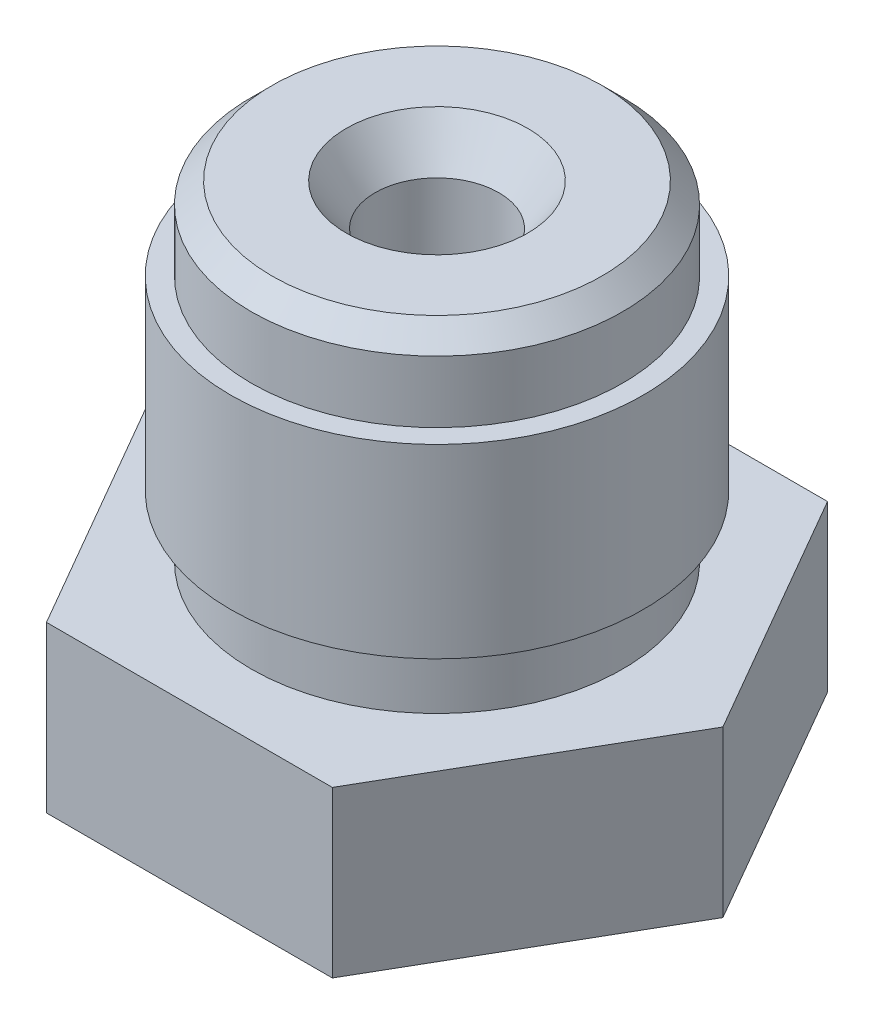
from build123d import *

# Parameters (mm, degrees)
SKETCH2_R           = 2.612661588
BOSS_EXTRUDE1_DEPTH = 2
CHAMFER1_SIZE       = 0.25


with BuildPart() as part:
    # Sketch1 → Revolve1 (revolve)
    with BuildSketch(Plane.XY):
        Polygon((0.2, -3.5), (0.2, -2.9), (0.75, -1.947372056), (0.75, 3), (1.100103769, 3.5), (2.25, 3.5), (2.25, 2.5), (2.5, 2.5), (2.5, 0.25), (2.25, 0.25), (2.25, -0.5), (3, -0.5), (3, -2.5), (1.100207538, -2.5), (0.4, -3.5), align=None)
    revolve(axis=Axis((0, -3.5, 0), (0, 1, 0)))

    # Sketch2 → Boss-Extrude1 (add)
    with BuildSketch(Plane.XZ.offset(2.5)):
        Polygon((1.732050808, 3), (-1.732050808, 3), (-3.464101615, 0), (-1.732050808, -3), (1.732050808, -3), (3.464101615, 0), align=None)
        Circle(SKETCH2_R, mode=Mode.SUBTRACT)
    extrude(amount=-BOSS_EXTRUDE1_DEPTH)

    # Chamfer1
    chamfer1_edges = [part.edges().sort_by_distance(p)[0] for p in [
        (-2.25, 3.5, 0),
    ]]
    chamfer(chamfer1_edges, length=CHAMFER1_SIZE)


solid = part.part
